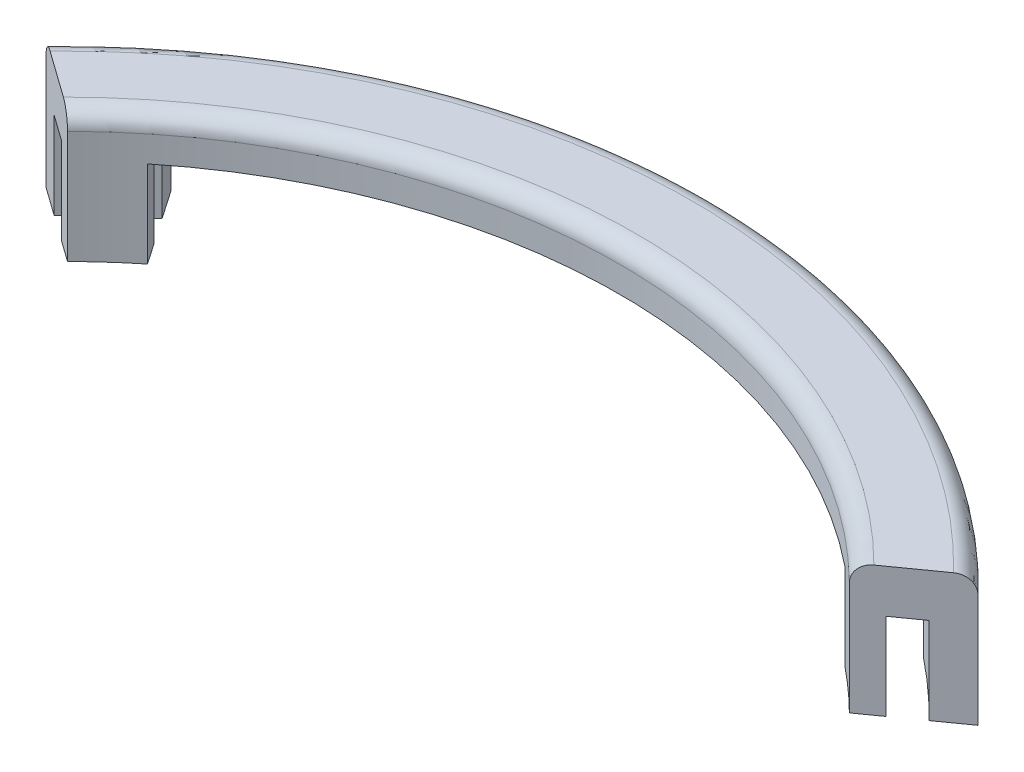
from build123d import *

# Parameters (mm, degrees)
BOSS_EXTRUDE1_DEPTH = 19.05
CUT_EXTRUDE1_DEPTH  = 12.7
FILLET1_R           = 2.54
CUT_EXTRUDE2_DEPTH  = 12.7


with BuildPart() as part:
    # Sketch1 → Boss-Extrude1 (new body)
    with BuildSketch(Plane(origin=(0, 0, 0), x_dir=(1, 0, 0), z_dir=(0, 1, 0))):
        with BuildLine():
            Line((57.234735331, 57.711554056), (68.22559355, 65.553540024))
            ThreePointArc((68.22559355, 65.553540024), (0, 94.615), (-68.22559355, 65.553540024))
            Line((-68.22559355, 65.553540024), (-57.234735331, 57.711554056))
            ThreePointArc((-57.234735331, 57.711554056), (0, 81.28), (57.234735331, 57.711554056))
        make_face()
    extrude(amount=BOSS_EXTRUDE1_DEPTH)

    # Sketch3 → Cut-Extrude1 (cut)
    with BuildSketch(Plane.XZ):
        with BuildLine():
            Line((-60.379405736, -59.955278859), (-64.043453365, -62.569579718))
            ThreePointArc((-64.043453365, -62.569579718), (0, -89.535), (64.043453365, -62.569579718))
            Line((64.043453365, -62.569579718), (60.379405736, -59.955278859))
            ThreePointArc((60.379405736, -59.955278859), (0, -85.09), (-60.379405736, -59.955278859))
        make_face()
    extrude(amount=-CUT_EXTRUDE1_DEPTH, mode=Mode.SUBTRACT)

    # Fillet1
    fillet1_edges = [part.edges().sort_by_distance(p)[0] for p in [
        (0, 19.05, -81.28),
        (0, 19.05, -94.615),
    ]]
    fillet(fillet1_edges, radius=FILLET1_R)

    # Sketch5 → Cut-Extrude2 (cut)
    with BuildSketch(Plane(origin=(0, 0, 0), x_dir=(-1, 0, 0), z_dir=(0, 1, 0))):
        with BuildLine():
            ThreePointArc((-49.614735331, -61.142175608), (0, -78.74), (49.614735331, -61.142175608))
            Line((49.614735331, -61.142175608), (58.988817486, -74.785572884))
            ThreePointArc((58.988817486, -74.785572884), (0, -95.25), (-58.988817486, -74.785572884))
            Line((-58.988817486, -74.785572884), (-49.614735331, -61.142175608))
        make_face()
    extrude(amount=CUT_EXTRUDE2_DEPTH, mode=Mode.SUBTRACT)


solid = part.part
